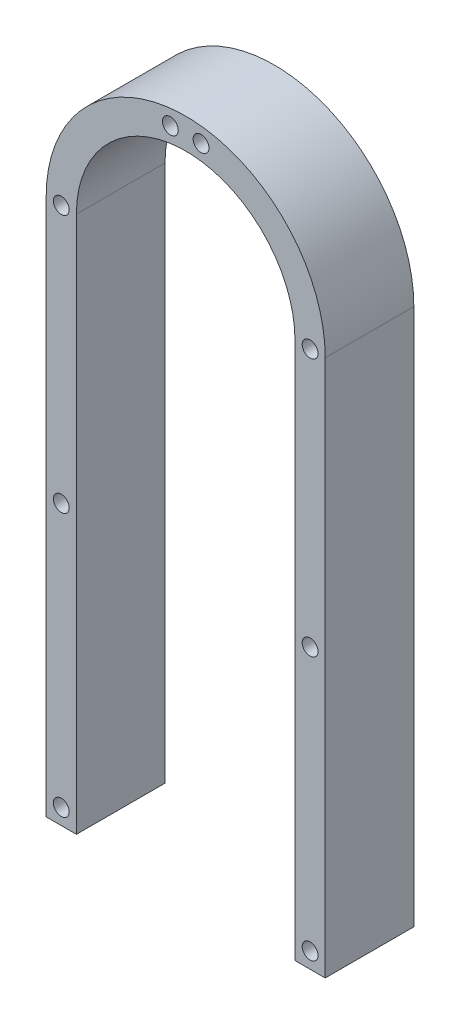
from build123d import *

# Parameters (mm, degrees)
BOSS_EXTRUDE1_DEPTH = 19.05
SKETCH2_R           = 1.7
CUT_EXTRUDE1_DEPTH  = 20.05
CUT_EXTRUDE2_DEPTH  = 20.05


with BuildPart() as part:
    # Sketch1 → Boss-Extrude1 (new body)
    with BuildSketch(Plane.XY):
        with BuildLine():
            Line((-179.085368151, -18.789194183), (-179.085368151, 212.188334746))
            ThreePointArc((-179.085368151, 212.188334746), (-149.085368151, 242.188334746), (-119.085368151, 212.188334746))
            Line((-119.085368151, 212.188334746), (-119.085368151, -18.789194183))
            ThreePointArc((-119.085368151, -18.789194183), (-149.085368151, -48.789194183), (-179.085368151, -18.789194183))
        make_face()
        with BuildLine():
            Line((-172.585368151, -18.789194183), (-172.585368151, 212.188334746))
            ThreePointArc((-172.585368151, 212.188334746), (-149.085368151, 235.688334746), (-125.585368151, 212.188334746))
            Line((-125.585368151, 212.188334746), (-125.585368151, -18.789194183))
            ThreePointArc((-125.585368151, -18.789194183), (-149.085368151, -42.289194183), (-172.585368151, -18.789194183))
        make_face(mode=Mode.SUBTRACT)
    extrude(amount=BOSS_EXTRUDE1_DEPTH)

    # Sketch2 → Cut-Extrude1 (cut, through all)
    with BuildSketch(Plane.XY.offset(19.05)):
        with Locations((-145.785368151, 238.734002942)):
            Circle(SKETCH2_R)
        with Locations((-122.335368151, 212.188334746)):
            Circle(SKETCH2_R)
        with Locations((-152.485368151, -45.322239617)):
            Circle(SKETCH2_R)
        with Locations((-168.000474547, -37.70430058)):
            Circle(SKETCH2_R)
        with Locations((-175.835368151, -18.789194183)):
            Circle(SKETCH2_R)
        with Locations((-175.835368151, 212.188334746)):
            Circle(SKETCH2_R)
        with Locations((-145.685368151, -45.322239617)):
            Circle(SKETCH2_R)
        with Locations((-175.835368151, 100.099570281)):
            Circle(SKETCH2_R)
        with Locations((-175.835368151, 93.299570281)):
            Circle(SKETCH2_R)
        with Locations((-122.335368151, 100.099570281)):
            Circle(SKETCH2_R)
        with Locations((-122.335368151, 93.299570281)):
            Circle(SKETCH2_R)
        with Locations((-122.335368151, -18.789194183)):
            Circle(SKETCH2_R)
        with Locations((-130.170261754, -37.70430058)):
            Circle(SKETCH2_R)
        with Locations((-175.835368151, 156.699570281)):
            Circle(SKETCH2_R)
        with Locations((-122.335368151, 156.699570281)):
            Circle(SKETCH2_R)
        with Locations((-175.835368151, 66.699570281)):
            Circle(SKETCH2_R)
        with Locations((-122.335368151, 66.699570281)):
            Circle(SKETCH2_R)
        with Locations((-175.835368151, 36.699570281)):
            Circle(SKETCH2_R)
        with Locations((-122.335368151, 36.699570281)):
            Circle(SKETCH2_R)
        with Locations((-175.835368151, 6.699570281)):
            Circle(SKETCH2_R)
        with Locations((-122.335368151, 6.699570281)):
            Circle(SKETCH2_R)
        with Locations((-152.385368151, 238.734002942)):
            Circle(SKETCH2_R)
    extrude(amount=-CUT_EXTRUDE1_DEPTH, mode=Mode.SUBTRACT)

    # Sketch3 → Cut-Extrude2 (cut, through all)
    with BuildSketch(Plane.XY.offset(19.05)):
        Polygon((-149.085368151, 96.699570281), (-100.167336626, 96.699570281), (-100.167336626, -59.171887956), (-212.527814826, -59.171887956), (-212.527814826, 96.699570281), align=None)
    extrude(amount=-CUT_EXTRUDE2_DEPTH, mode=Mode.SUBTRACT)


solid = part.part
